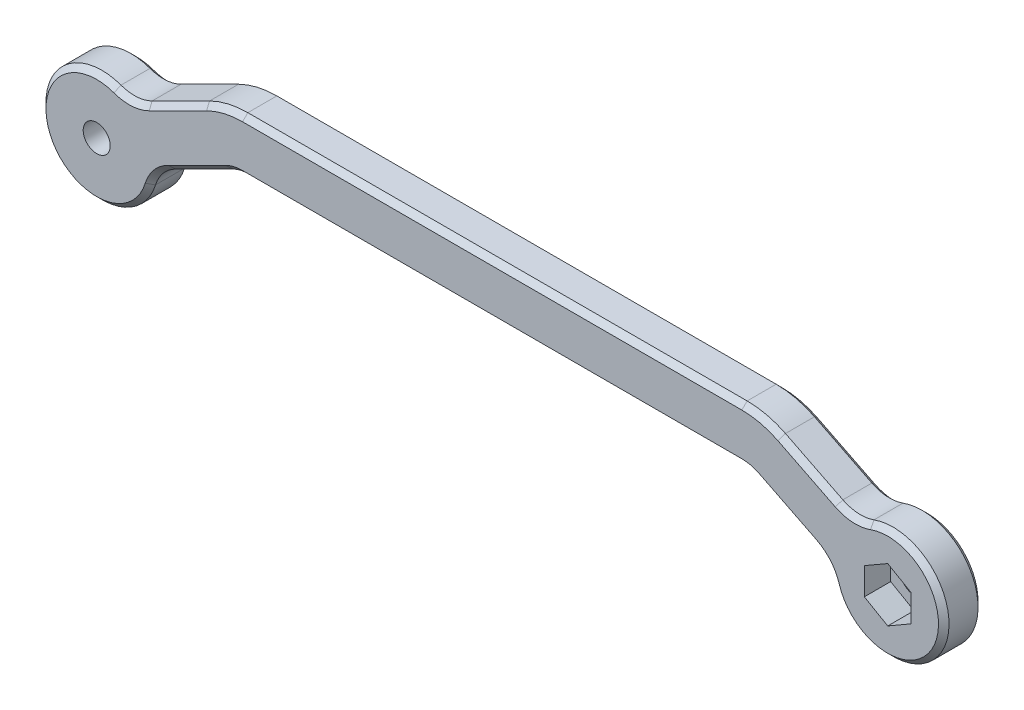
from build123d import *

# Parameters (mm, degrees)
SKETCH1_R           = 2.05
BOSS_EXTRUDE1_DEPTH = 6
CUT_EXTRUDE1_DEPTH  = 4
CHAMFER3_SIZE       = 0.8


with BuildPart() as part:
    # Sketch1 → Boss-Extrude1 (new body)
    with BuildSketch(Plane.XY):
        with BuildLine():
            Line((-52.397368877, 8.273451517), (-43.689164944, 12.627553483))
            ThreePointArc((-43.689164944, 12.627553483), (-40.86217617, 13.652236863), (-37.875388203, 14))
            Line((-37.875388203, 14), (37.875388203, 14))
            ThreePointArc((37.875388203, 14), (40.86217617, 13.652236863), (43.689164944, 12.627553483))
            Line((43.689164944, 12.627553483), (52.397368877, 8.273451517))
            ThreePointArc((52.397368877, 8.273451517), (54.728318318, 7.650368424), (57.116243367, 7.995870664))
            ThreePointArc((57.116243367, 7.995870664), (67.602631123, -3.801315562), (51.873049489, -2.490517092))
            ThreePointArc((51.873049489, -2.490517092), (50.716696252, -0.372875708), (48.819660113, 1.118033989))
            Line((48.819660113, 1.118033989), (40.11145618, 5.472135955))
            ThreePointArc((40.11145618, 5.472135955), (39.024152805, 5.866244947), (37.875388203, 6))
            Line((37.875388203, 6), (-37.875388203, 6))
            ThreePointArc((-37.875388203, 6), (-39.024152805, 5.866244947), (-40.11145618, 5.472135955))
            Line((-40.11145618, 5.472135955), (-48.819660113, 1.118033989))
            ThreePointArc((-48.819660113, 1.118033989), (-50.716696252, -0.372875708), (-51.873049489, -2.490517092))
            ThreePointArc((-51.873049489, -2.490517092), (-67.602631123, -3.801315562), (-57.116243367, 7.995870664))
            ThreePointArc((-57.116243367, 7.995870664), (-54.728318318, 7.650368424), (-52.397368877, 8.273451517))
        make_face()
        with Locations((-60, 0)):
            Circle(SKETCH1_R, mode=Mode.SUBTRACT)
        with Locations((60, 0)):
            Circle(SKETCH1_R, mode=Mode.SUBTRACT)
    extrude(amount=BOSS_EXTRUDE1_DEPTH)

    # Sketch3 → Cut-Extrude1 (cut)
    with BuildSketch(Plane.XY.offset(6)):
        Polygon((60, 4.099186911), (56.45, 2.049593456), (56.45, -2.049593456), (60, -4.099186911), (63.55, -2.049593456), (63.55, 2.049593456), align=None)
    extrude(amount=-CUT_EXTRUDE1_DEPTH, mode=Mode.SUBTRACT)

    # Chamfer3
    chamfer3_edges = [part.edges().sort_by_distance(p)[0] for p in [
        (-40.86217617, 13.652236863, 6),
        (48.04326691, 10.4505025, 0),
        (54.728318318, 7.650368424, 0),
        (67.602631123, -3.801315562, 0),
        (-48.04326691, 10.4505025, 6),
        (50.716696252, -0.372875708, 0),
        (44.465558146, 3.295084972, 0),
        (39.024152805, 5.866244947, 0),
        (0, 6, 0),
        (-39.024152805, 5.866244947, 0),
        (-44.465558146, 3.295084972, 0),
        (-50.716696252, -0.372875708, 0),
        (-67.602631123, -3.801315562, 0),
        (-54.728318318, 7.650368424, 0),
        (-48.04326691, 10.4505025, 0),
        (-54.728318318, 7.650368424, 6),
        (-40.86217617, 13.652236863, 0),
        (0, 14, 0),
        (40.86217617, 13.652236863, 0),
        (-67.602631123, -3.801315562, 6),
        (-50.716696252, -0.372875708, 6),
        (-44.465558146, 3.295084972, 6),
        (-39.024152805, 5.866244947, 6),
        (0, 6, 6),
        (39.024152805, 5.866244947, 6),
        (44.465558146, 3.295084972, 6),
        (40.86217617, 13.652236863, 6),
        (50.716696252, -0.372875708, 6),
        (67.602631123, -3.801315562, 6),
        (54.728318318, 7.650368424, 6),
        (48.04326691, 10.4505025, 6),
        (0, 14, 6),
    ]]
    chamfer(chamfer3_edges, length=CHAMFER3_SIZE)


solid = part.part
